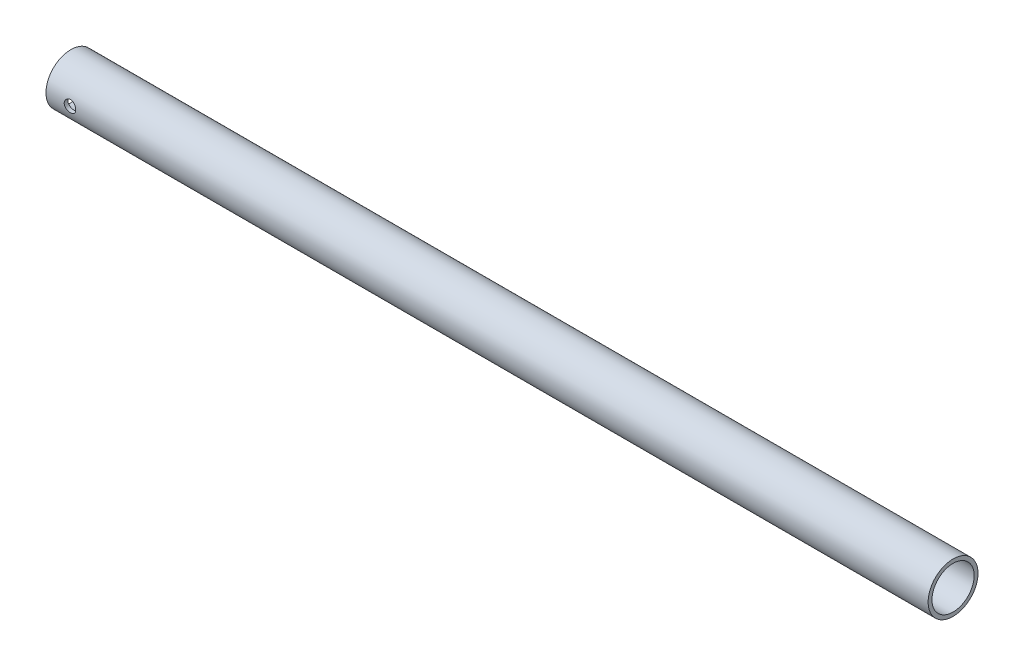
from build123d import *

# Parameters (mm, degrees)
SKETCH_1_R          = 13
SKETCH_1_R_2        = 11
EXTRUDE_1_DEPTH     = 460
SKETCH_4_R          = 1.5
CUT_EXTRUDE_2_DEPTH = 14
SKETCH_6_R          = 3
CUT_EXTRUDE_3_DEPTH = 14.0000001


with BuildPart() as part:
    # 草图1 → 凸台-拉伸1 (new body)
    with BuildSketch(Plane(origin=(0, 0, 0), x_dir=(0, 0, -1), z_dir=(1, 0, 0))):
        Circle(SKETCH_1_R)
        Circle(SKETCH_1_R_2, mode=Mode.SUBTRACT)
    extrude(amount=EXTRUDE_1_DEPTH)

    # 草图4 → 切除-拉伸2 (cut, through all)
    with BuildSketch(Plane(origin=(0, 0, 0), x_dir=(1, 0, 0), z_dir=(0, 1, 0))):
        with Locations((12.5, 0)):
            Circle(SKETCH_4_R)
        with Locations((441.5, 0)):
            Circle(SKETCH_4_R)
    extrude(amount=-CUT_EXTRUDE_2_DEPTH, mode=Mode.SUBTRACT)

    # 草图6 → 切除-拉伸3 (cut, through all)
    with BuildSketch(Plane.XY):
        with Locations((12.5, 0)):
            Circle(SKETCH_6_R)
    extrude(amount=CUT_EXTRUDE_3_DEPTH, mode=Mode.SUBTRACT)


solid = part.part
